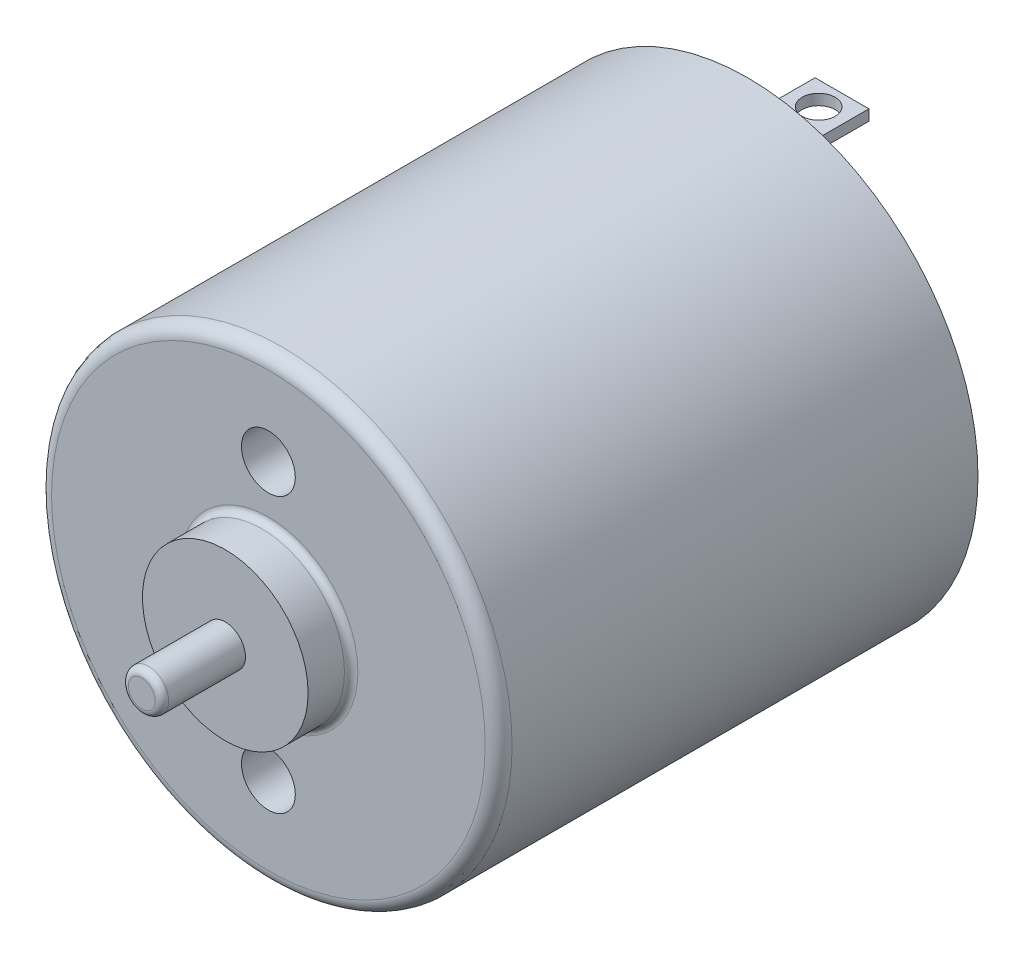
from build123d import *

# Parameters (mm, degrees)
SKETCH1_R           = 8.55
BOSS_EXTRUDE1_DEPTH = 17.8
SKETCH2_R           = 3.075
BOSS_EXTRUDE2_DEPTH = 1.6
SKETCH3_R           = 0.75
BOSS_EXTRUDE3_DEPTH = 3.1
SKETCH4_R           = 1
CUT_EXTRUDE1_DEPTH  = 2
SKETCH5_R           = 2.35
BOSS_EXTRUDE4_DEPTH = 2.16
SKETCH6_W           = 2
SKETCH6_H           = 0.4
BOSS_EXTRUDE5_DEPTH = 3.5
FILLET1_R           = 0.5
FILLET2_R           = 0.25
FILLET3_R           = 0.5
SKETCH7_R           = 8.3
CUT_EXTRUDE2_DEPTH  = 0.5
SKETCH8_R           = 0.613220663
CUT_EXTRUDE3_DEPTH  = 15.5
FILLET4_R           = 0.25


with BuildPart() as part:
    # Sketch1 → Boss-Extrude1 (new body)
    with BuildSketch(Plane.XY):
        Circle(SKETCH1_R)
    extrude(amount=BOSS_EXTRUDE1_DEPTH)

    # Sketch2 → Boss-Extrude2 (add)
    with BuildSketch(Plane.XY.offset(17.8)):
        Circle(SKETCH2_R)
    extrude(amount=BOSS_EXTRUDE2_DEPTH)

    # Sketch3 → Boss-Extrude3 (add)
    with BuildSketch(Plane.XY.offset(19.4)):
        Circle(SKETCH3_R)
    extrude(amount=BOSS_EXTRUDE3_DEPTH)

    # Sketch4 → Cut-Extrude1 (cut)
    with BuildSketch(Plane.XY.offset(17.8)):
        with Locations((0, 5.1)):
            Circle(SKETCH4_R)
        with Locations((0, -5.1)):
            Circle(SKETCH4_R)
    extrude(amount=-CUT_EXTRUDE1_DEPTH, mode=Mode.SUBTRACT)

    # Sketch5 → Boss-Extrude4 (add)
    with BuildSketch(Plane(origin=(0, 0, 0), x_dir=(-1, 0, 0), z_dir=(0, 0, -1))):
        Circle(SKETCH5_R)
    extrude(amount=BOSS_EXTRUDE4_DEPTH)

    # Sketch6 → Boss-Extrude5 (add)
    with BuildSketch(Plane(origin=(0, 0, 0), x_dir=(-1, 0, 0), z_dir=(0, 0, -1))):
        with Locations((0, 6.1)):
            Rectangle(SKETCH6_W, SKETCH6_H)
        with Locations((0, -6.1)):
            Rectangle(SKETCH6_W, SKETCH6_H)
    extrude(amount=BOSS_EXTRUDE5_DEPTH)

    # Fillet1
    fillet1_edges = [part.edges().sort_by_distance(p)[0] for p in [
        (-8.55, 0, 17.8),
    ]]
    fillet(fillet1_edges, radius=FILLET1_R)

    # Fillet2
    fillet2_edges = [part.edges().sort_by_distance(p)[0] for p in [
        (-3.075, 0, 17.8),
    ]]
    fillet(fillet2_edges, radius=FILLET2_R)

    # Fillet3
    fillet3_edges = [part.edges().sort_by_distance(p)[0] for p in [
        (2.35, 0, -2.16),
    ]]
    fillet(fillet3_edges, radius=FILLET3_R)

    # Sketch7 → Cut-Extrude2 (cut)
    with BuildSketch(Plane(origin=(0, 0, 0), x_dir=(-1, 0, 0), z_dir=(0, 0, -1))):
        Circle(SKETCH7_R)
    extrude(amount=-CUT_EXTRUDE2_DEPTH, mode=Mode.SUBTRACT)

    # Sketch8 → Cut-Extrude3 (cut)
    with BuildSketch(Plane(origin=(0, 6.3, 0), x_dir=(1, 0, 0), z_dir=(0, 1, 0))):
        with Locations((0, 2.632929707)):
            Circle(SKETCH8_R)
    extrude(amount=-CUT_EXTRUDE3_DEPTH, mode=Mode.SUBTRACT)

    # Fillet4
    fillet4_edges = [part.edges().sort_by_distance(p)[0] for p in [
        (-0.75, 0, 22.5),
    ]]
    fillet(fillet4_edges, radius=FILLET4_R)


solid = part.part
